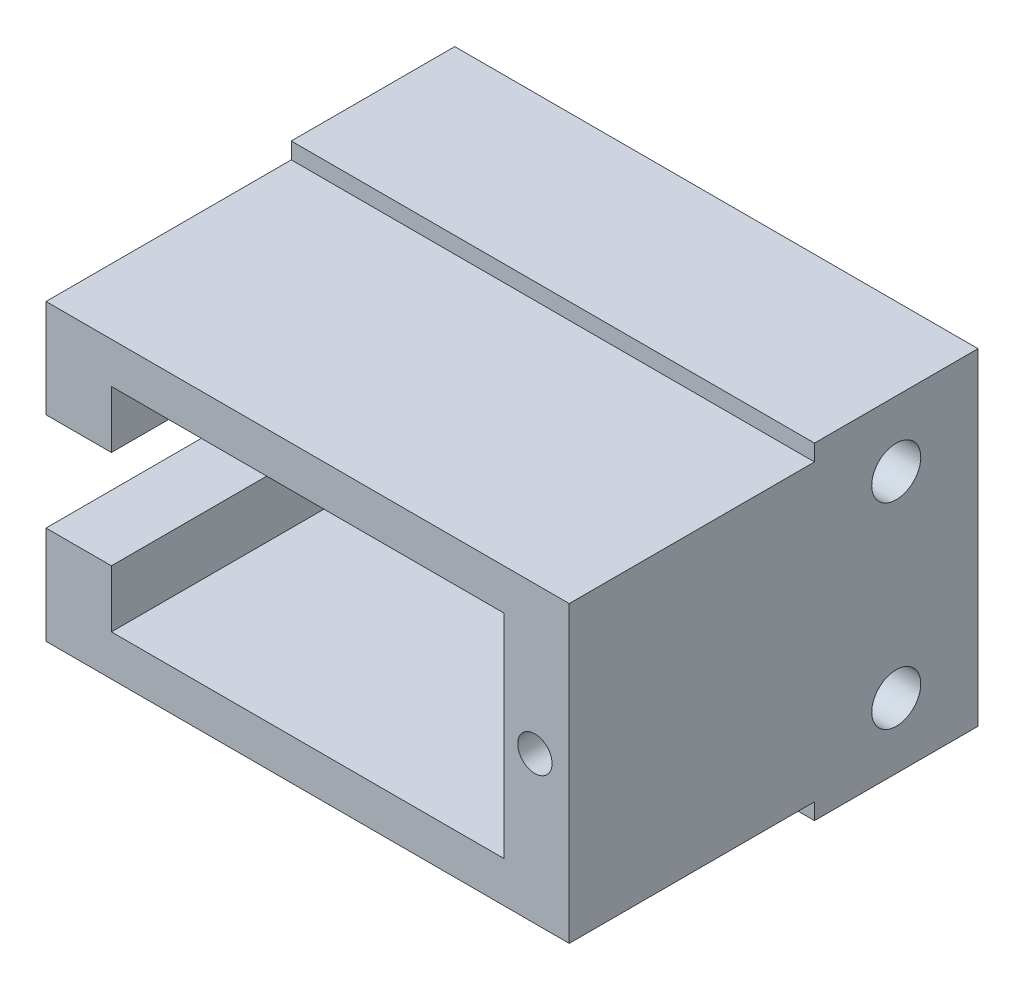
from build123d import *

# Parameters (mm, degrees)
ESQUISSE15_W             = 32
ESQUISSE15_H             = 20
BOSS_EXTRU_1_DEPTH       = 10
ESQUISSE16_W             = 32
ESQUISSE16_H             = 18
ESQUISSE16_W_2           = 24
ESQUISSE16_H_2           = 13
BOSS_EXTRU_2_DEPTH       = 15
ESQUISSE17_W             = 25
ESQUISSE17_H             = 6
ENL_V_MAT_EXTRU_8_DEPTH  = 4
ESQUISSE19_R             = 1.05
ENL_V_MAT_EXTRU_10_DEPTH = 6
ESQUISSE20_R             = 1.5
ENL_V_MAT_EXTRU_11_DEPTH = 20


with BuildPart() as part:
    # Esquisse15 → Boss.-Extru.1 (new body)
    with BuildSketch(Plane.XY):
        Rectangle(ESQUISSE15_W, ESQUISSE15_H)
    extrude(amount=BOSS_EXTRU_1_DEPTH)

    # Esquisse16 → Boss.-Extru.2 (add)
    with BuildSketch(Plane.XY.offset(10)):
        Rectangle(ESQUISSE16_W, ESQUISSE16_H)
        Rectangle(ESQUISSE16_W_2, ESQUISSE16_H_2, mode=Mode.SUBTRACT)
    extrude(amount=BOSS_EXTRU_2_DEPTH)

    # Esquisse17 → Enlèv. mat.-Extru.8 (cut)
    with BuildSketch(Plane.ZY.offset(16)):
        with Locations((12.5, 0)):
            Rectangle(ESQUISSE17_W, ESQUISSE17_H)
    extrude(amount=-ENL_V_MAT_EXTRU_8_DEPTH, mode=Mode.SUBTRACT)

    # Esquisse19 → Enlèv. mat.-Extru.10 (cut)
    with BuildSketch(Plane.XY.offset(25)):
        with Locations((13.9, 0)):
            Circle(ESQUISSE19_R)
    extrude(amount=-ENL_V_MAT_EXTRU_10_DEPTH, mode=Mode.SUBTRACT)

    # Esquisse20 → Enlèv. mat.-Extru.11 (cut)
    with BuildSketch(Plane(origin=(16, 0, 0), x_dir=(0, 0, -1), z_dir=(1, 0, 0))):
        with Locations((-5, 6)):
            Circle(ESQUISSE20_R)
        with Locations((-5, -6)):
            Circle(ESQUISSE20_R)
    extrude(amount=-ENL_V_MAT_EXTRU_11_DEPTH, mode=Mode.SUBTRACT)


solid = part.part
